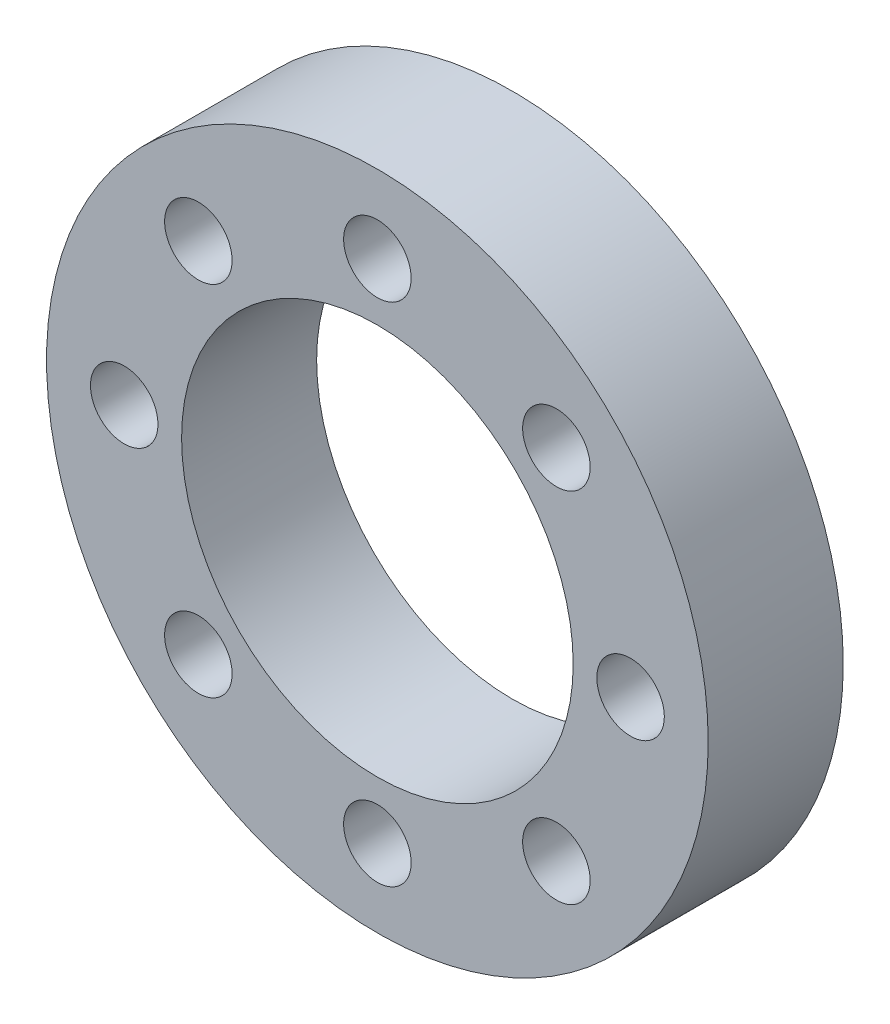
from build123d import *

# Parameters (mm, degrees)
SKETCH1_R           = 9.8
SKETCH1_R_2         = 5.8
BOSS_EXTRUDE1_DEPTH = 4
SKETCH2_R           = 1
CUT_EXTRUDE1_DEPTH  = 5


with BuildPart() as part:
    # Sketch1 → Boss-Extrude1 (new body)
    with BuildSketch(Plane.XY):
        Circle(SKETCH1_R)
        Circle(SKETCH1_R_2, mode=Mode.SUBTRACT)
    extrude(amount=BOSS_EXTRUDE1_DEPTH)

    # Sketch2 → Cut-Extrude1 (cut, through all)
    with BuildSketch(Plane.XY.offset(4)):
        with Locations((0, 7.5)):
            Circle(SKETCH2_R)
        with Locations((7.5, 0)):
            Circle(SKETCH2_R)
        with Locations((0, -7.5)):
            Circle(SKETCH2_R)
        with Locations((-7.5, 0)):
            Circle(SKETCH2_R)
        with Locations((-5.303300859, 5.303300859)):
            Circle(SKETCH2_R)
        with Locations((5.303300859, 5.303300859)):
            Circle(SKETCH2_R)
        with Locations((5.303300859, -5.303300859)):
            Circle(SKETCH2_R)
        with Locations((-5.303300859, -5.303300859)):
            Circle(SKETCH2_R)
    extrude(amount=-CUT_EXTRUDE1_DEPTH, mode=Mode.SUBTRACT)


solid = part.part
